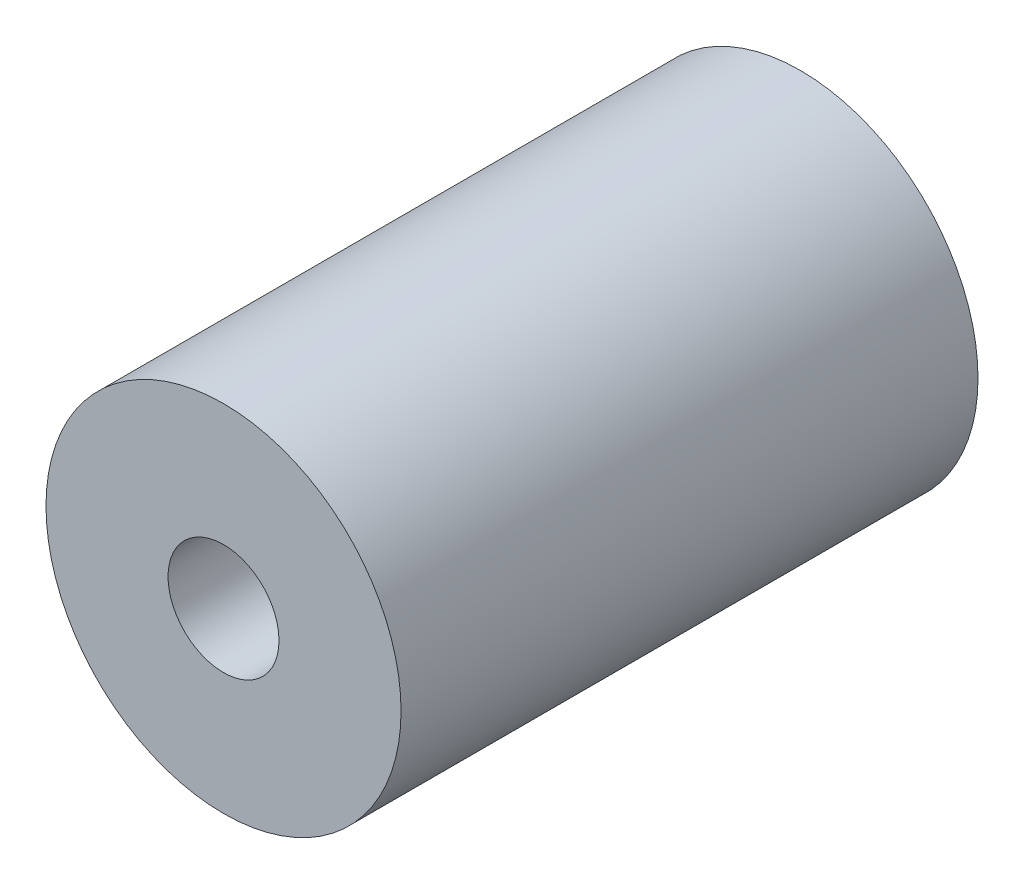
from build123d import *

# Parameters (mm, degrees)
SKETCH1_R           = 8
SKETCH1_R_2         = 2.5
BOSS_EXTRUDE1_DEPTH = 26


with BuildPart() as part:
    # Sketch1 → Boss-Extrude1 (new body)
    with BuildSketch(Plane.XY):
        Circle(SKETCH1_R)
        Circle(SKETCH1_R_2, mode=Mode.SUBTRACT)
    extrude(amount=BOSS_EXTRUDE1_DEPTH)


solid = part.part
